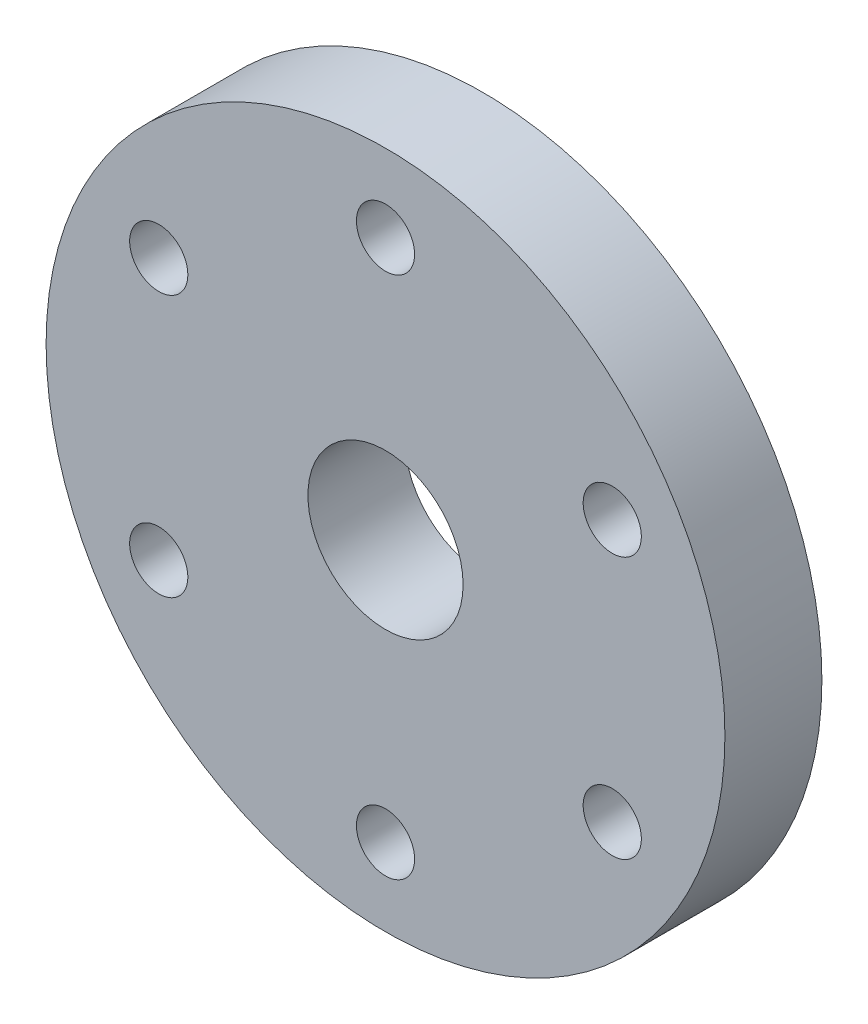
from build123d import *

# Parameters (mm, degrees)
SKETCH_1_R          = 17.5
EXTRUDE_1_DEPTH     = 5
SKETCH_2_R          = 1.5
SKETCH_2_R_2        = 4
CUT_EXTRUDE_1_DEPTH = 5


with BuildPart() as part:
    # 草图1 → 凸台-拉伸1 (new body)
    with BuildSketch(Plane.XY):
        Circle(SKETCH_1_R)
    extrude(amount=EXTRUDE_1_DEPTH)

    # 草图2 → 切除-拉伸1 (cut)
    with BuildSketch(Plane.XY.offset(5)):
        with Locations((0, 13.5)):
            Circle(SKETCH_2_R)
        with Locations((11.691342951, 6.75)):
            Circle(SKETCH_2_R)
        with Locations((11.691342951, -6.75)):
            Circle(SKETCH_2_R)
        Circle(SKETCH_2_R_2)
        with Locations((0, -13.5)):
            Circle(SKETCH_2_R)
        with Locations((-11.691342951, -6.75)):
            Circle(SKETCH_2_R)
        with Locations((-11.691342951, 6.75)):
            Circle(SKETCH_2_R)
    extrude(amount=-CUT_EXTRUDE_1_DEPTH, mode=Mode.SUBTRACT)


solid = part.part
